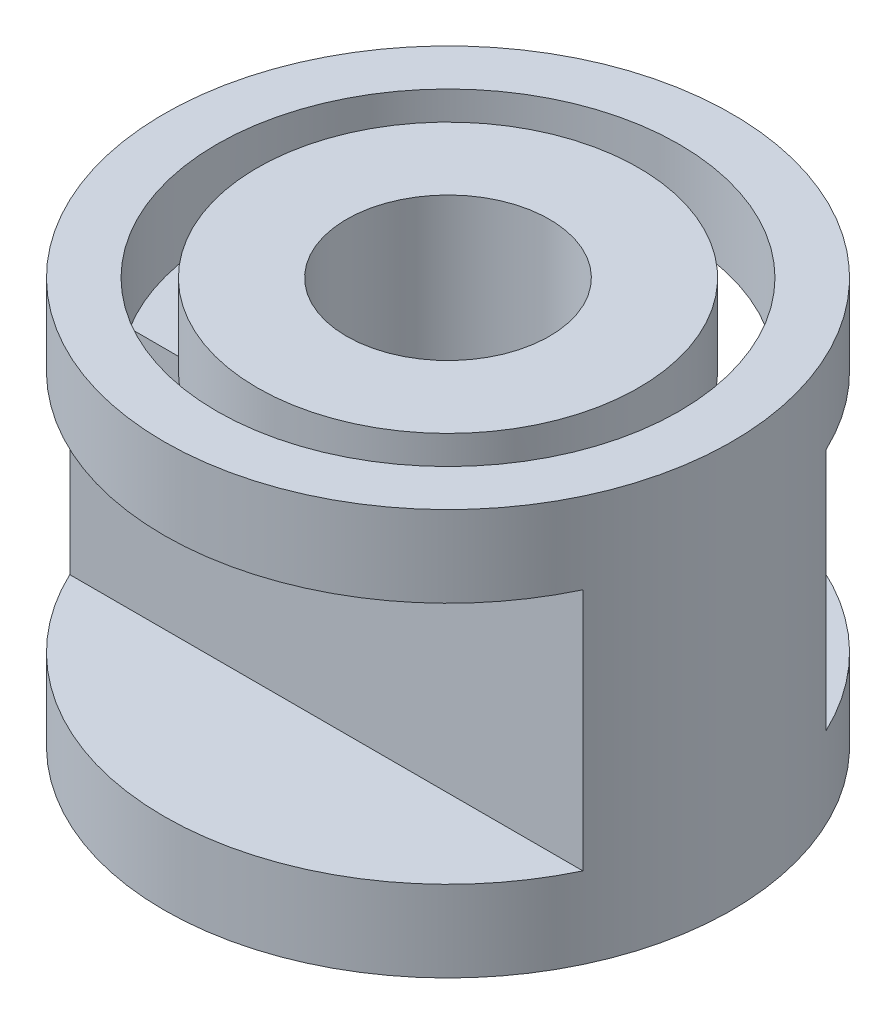
from build123d import *

# Parameters (mm, degrees)
ESQUISSE1_R                  = 3.5
BOSS_EXTRU_1_DEPTH           = 5
ESQUISSE2_R                  = 2.85
ESQUISSE2_R_2                = 2.35
ENL_V_MAT_EXTRU_1_DEPTH      = 1
ESQUISSE3_R                  = 1.25
ENL_V_MAT_EXTRU_2_DEPTH      = 6
ESQUISSE4_W                  = 2
ESQUISSE4_H                  = 3
ENL_V_MAT_EXTRU_3_DEPTH      = 4.5
ENL_V_MAT_EXTRU_3_DEPTH_BACK = 4.5


with BuildPart() as part:
    # Esquisse1 → Boss.-Extru.1 (new body)
    with BuildSketch(Plane(origin=(0, 0, 0), x_dir=(1, 0, 0), z_dir=(0, 1, 0))):
        Circle(ESQUISSE1_R)
    extrude(amount=BOSS_EXTRU_1_DEPTH)

    # Esquisse2 → Enlèv. mat.-Extru.1 (cut)
    with BuildSketch(Plane(origin=(0, 5, 0), x_dir=(1, 0, 0), z_dir=(0, 1, 0))):
        Circle(ESQUISSE2_R)
        Circle(ESQUISSE2_R_2, mode=Mode.SUBTRACT)
    extrude(amount=-ENL_V_MAT_EXTRU_1_DEPTH, mode=Mode.SUBTRACT)

    # Esquisse3 → Enlèv. mat.-Extru.2 (cut, through all)
    with BuildSketch(Plane(origin=(0, 5, 0), x_dir=(1, 0, 0), z_dir=(0, 1, 0))):
        Circle(ESQUISSE3_R)
    extrude(amount=-ENL_V_MAT_EXTRU_2_DEPTH, mode=Mode.SUBTRACT)

    # Esquisse4 → Enlèv. mat.-Extru.3 (cut, two sides)
    with BuildSketch(Plane(origin=(0, 0, 0), x_dir=(0, 0, -1), z_dir=(1, 0, 0))) as enl_v_mat_extru_3_sk:
        with Locations((-2.5, 2.5)):
            Rectangle(ESQUISSE4_W, ESQUISSE4_H)
        with Locations((2.5, 2.5)):
            Rectangle(ESQUISSE4_W, ESQUISSE4_H)
    extrude(amount=ENL_V_MAT_EXTRU_3_DEPTH, mode=Mode.SUBTRACT)
    extrude(enl_v_mat_extru_3_sk.sketch, amount=-ENL_V_MAT_EXTRU_3_DEPTH_BACK, mode=Mode.SUBTRACT)


solid = part.part
